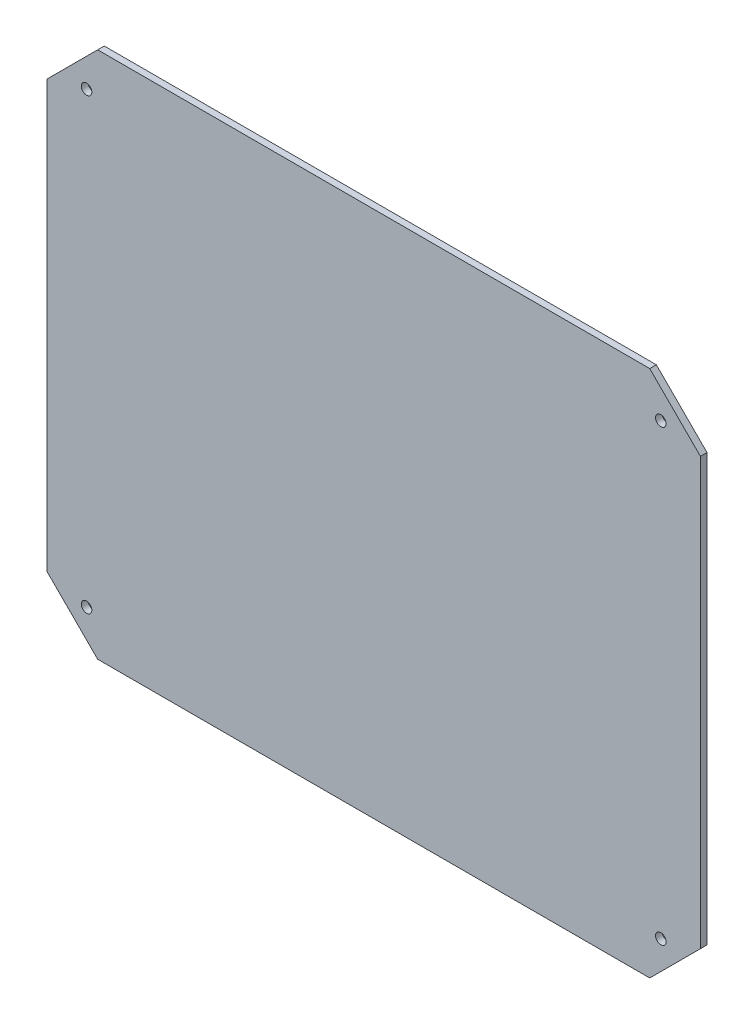
from build123d import *

# Parameters (mm, degrees)
ESQUISSE1_R        = 1.6
BOSS_EXTRU_1_DEPTH = 2


with BuildPart() as part:
    # Esquisse1 → Boss.-Extru.1 (new body)
    with BuildSketch(Plane.XY):
        Polygon((15.367, 0), (0, -15.367), (0, -144.653), (15.367, -160.02), (182.753, -160.02), (198.12, -144.653), (198.12, -15.367), (182.753, 0), align=None)
        with Locations((12, -12)):
            Circle(ESQUISSE1_R, mode=Mode.SUBTRACT)
        with Locations((12, -148.02)):
            Circle(ESQUISSE1_R, mode=Mode.SUBTRACT)
        with Locations((186.12, -12)):
            Circle(ESQUISSE1_R, mode=Mode.SUBTRACT)
        with Locations((186.12, -148.02)):
            Circle(ESQUISSE1_R, mode=Mode.SUBTRACT)
    extrude(amount=BOSS_EXTRU_1_DEPTH)


solid = part.part
